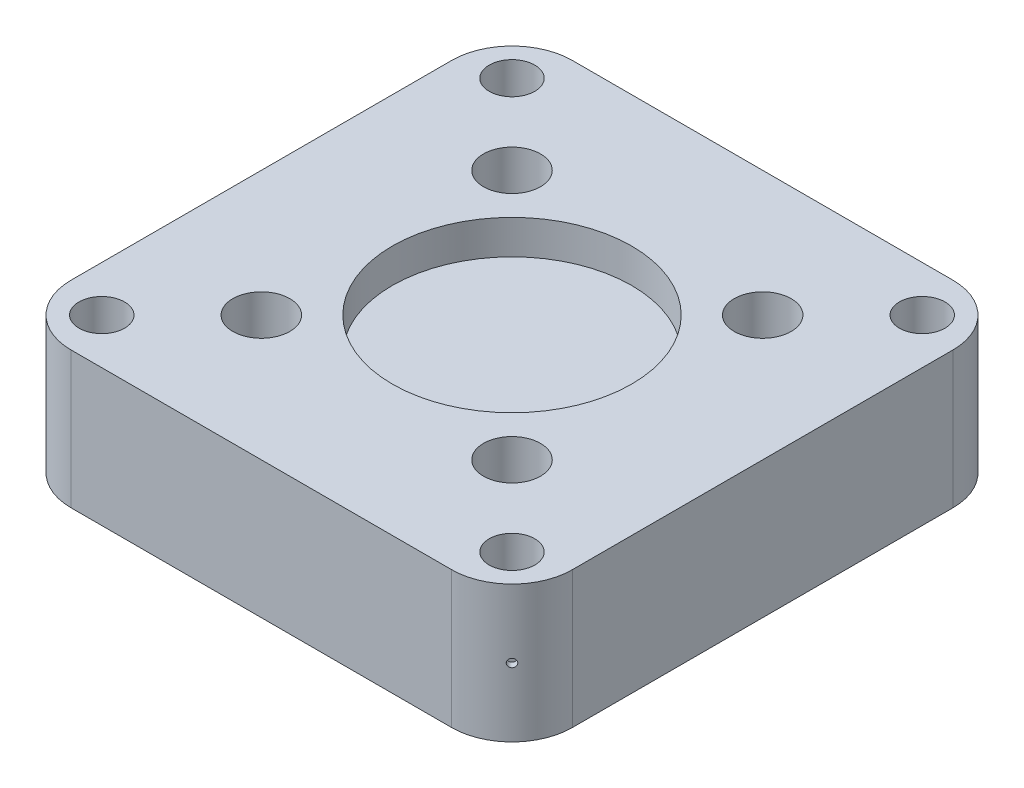
from build123d import *

# Parameters (mm, degrees)
IZIM1_R                     = 100
IZIM1_R_2                   = 125
Y_KSEKLIK_EKSTR_ZYON3_DEPTH = 600
IZIM2_R                     = 525
KES_EKSTR_ZYON1_DEPTH       = 150
IZIM3_R                     = 400
KES_EKSTR_ZYON2_DEPTH       = 200
IZIM4_R                     = 400
Y_KSEKLIK_EKSTR_ZYON4_DEPTH = 500
IZIM6_R                     = 18
KES_EKSTR_ZYON3_DEPTH       = 30
IZIM8_R                     = 18
KES_EKSTR_ZYON4_DEPTH       = 30
IZIM9_R                     = 18
KES_EKSTR_ZYON5_DEPTH       = 30
IZIM10_R                    = 18
KES_EKSTR_ZYON6_DEPTH       = 30


with BuildPart() as part:
    # Çizim1 → Yükseklik-Ekstrüzyon3 (new body)
    with BuildSketch(Plane(origin=(0, 0, 0), x_dir=(1, 0, 0), z_dir=(0, 1, 0))):
        with BuildLine():
            Line((-835, -1100), (835, -1100))
            ThreePointArc((835, -1100), (1022.383297014, -1022.383297014), (1100, -835))
            Line((1100, -835), (1100, 835))
            ThreePointArc((1100, 835), (1022.383297014, 1022.383297014), (835, 1100))
            Line((835, 1100), (-835, 1100))
            ThreePointArc((-835, 1100), (-1022.383297014, 1022.383297014), (-1100, 835))
            Line((-1100, 835), (-1100, -835))
            ThreePointArc((-1100, -835), (-1022.383297014, -1022.383297014), (-835, -1100))
        make_face()
        with Locations((-900, -900)):
            Circle(IZIM1_R, mode=Mode.SUBTRACT)
        with Locations((-900, 900)):
            Circle(IZIM1_R, mode=Mode.SUBTRACT)
        with Locations((900, 900)):
            Circle(IZIM1_R, mode=Mode.SUBTRACT)
        with Locations((900, -900)):
            Circle(IZIM1_R, mode=Mode.SUBTRACT)
        with Locations((-550, 550)):
            Circle(IZIM1_R_2, mode=Mode.SUBTRACT)
        with Locations((550, 550)):
            Circle(IZIM1_R_2, mode=Mode.SUBTRACT)
        with Locations((550, -550)):
            Circle(IZIM1_R_2, mode=Mode.SUBTRACT)
        with Locations((-550, -550)):
            Circle(IZIM1_R_2, mode=Mode.SUBTRACT)
    extrude(amount=Y_KSEKLIK_EKSTR_ZYON3_DEPTH)

    # Çizim2 → Kes-Ekstrüzyon1 (cut)
    with BuildSketch(Plane(origin=(0, 600, 0), x_dir=(1, 0, 0), z_dir=(0, 1, 0))):
        Circle(IZIM2_R)
    extrude(amount=-KES_EKSTR_ZYON1_DEPTH, mode=Mode.SUBTRACT)

    # Çizim3 → Kes-Ekstrüzyon2 (cut)
    with BuildSketch(Plane.XZ):
        Circle(IZIM3_R)
    extrude(amount=-KES_EKSTR_ZYON2_DEPTH, mode=Mode.SUBTRACT)

    # Çizim4 → Yükseklik-Ekstrüzyon4 (add)
    with BuildSketch(Plane.XZ.offset(-200)):
        Circle(IZIM4_R)
    extrude(amount=Y_KSEKLIK_EKSTR_ZYON4_DEPTH)

    # Çizim6 → Kes-Ekstrüzyon3 (cut)
    with BuildSketch(Plane(origin=(1022.383297014, 600, 1022.383297014), x_dir=(0.707106781, 0, -0.707106781), z_dir=(0.707106781, 0, 0.707106781))):
        with Locations((0, -300)):
            Circle(IZIM6_R)
    extrude(amount=-KES_EKSTR_ZYON3_DEPTH, mode=Mode.SUBTRACT)

    # Çizim8 → Kes-Ekstrüzyon4 (cut)
    with BuildSketch(Plane(origin=(1022.383297014, 600, -1022.383297014), x_dir=(-0.707106781, 0, -0.707106781), z_dir=(0.707106781, 0, -0.707106781))):
        with Locations((0, -300)):
            Circle(IZIM8_R)
    extrude(amount=-KES_EKSTR_ZYON4_DEPTH, mode=Mode.SUBTRACT)

    # Çizim9 → Kes-Ekstrüzyon5 (cut)
    with BuildSketch(Plane(origin=(-1022.383297014, 600, -1022.383297014), x_dir=(-0.707106781, 0, 0.707106781), z_dir=(-0.707106781, 0, -0.707106781))):
        with Locations((0, -300)):
            Circle(IZIM9_R)
    extrude(amount=-KES_EKSTR_ZYON5_DEPTH, mode=Mode.SUBTRACT)

    # Çizim10 → Kes-Ekstrüzyon6 (cut)
    with BuildSketch(Plane(origin=(-1022.383297014, 600, 1022.383297014), x_dir=(0.707106781, 0, 0.707106781), z_dir=(-0.707106781, 0, 0.707106781))):
        with Locations((0, -300)):
            Circle(IZIM10_R)
    extrude(amount=-KES_EKSTR_ZYON6_DEPTH, mode=Mode.SUBTRACT)


solid = part.part
